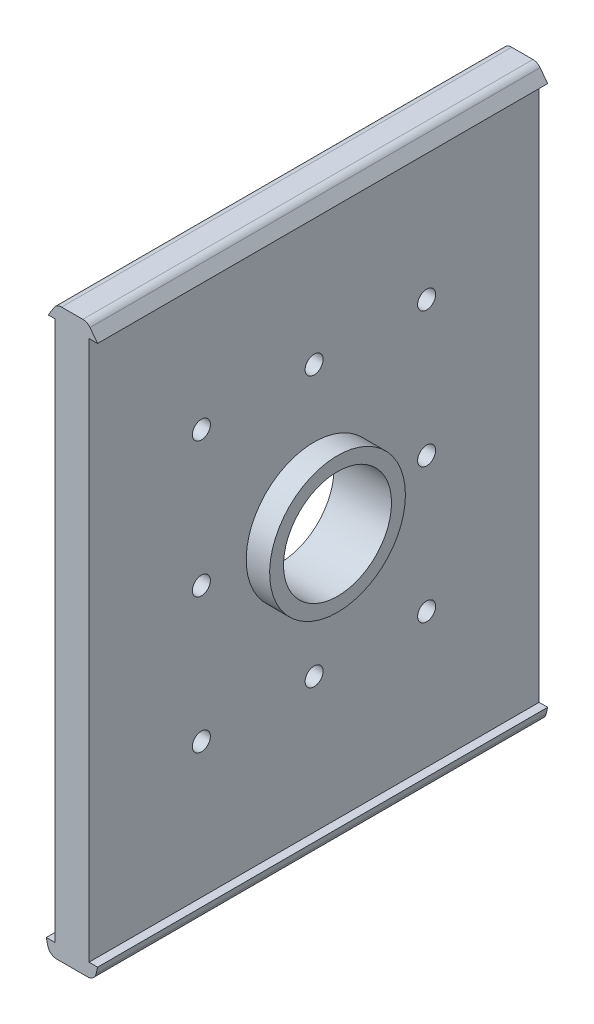
from build123d import *

# Parameters (mm, degrees)
RESSALTO_EXTRUS_O1_DEPTH   = 160
ESBO_O2_W                  = 7.6
ESBO_O2_H                  = 120
CORTE_EXTRUS_O1_DEPTH      = 30
CORTE_EXTRUS_O2_DEPTH      = 30
F_3DSKETCH3_R              = 2
CORTE_EXTRUS_O3_DEPTH      = 70
ESBO_O3_W                  = 45.015344868
ESBO_O3_H                  = 129.478543367
ESBO_O3_W_2                = 37.192593828
CORTE_EXTRUS_O4_DEPTH      = 31.510345968
CORTE_EXTRUS_O4_DEPTH_BACK = 38
ESBO_O4_R                  = 12
CORTE_EXTRUS_O5_DEPTH      = 52.510345968
CORTE_EXTRUS_O5_DEPTH_BACK = 54
ESBO_O5_R                  = 15.084668413
ESBO_O5_R_2                = 12
RESSALTO_EXTRUS_O3_DEPTH   = 9


with BuildPart() as part:
    # Esboço1 → Ressalto-extrusão1 (new body)
    with BuildSketch(Plane.XY):
        with BuildLine():
            Line((-3.8, 21.821375341), (-3.8, -98.178624659))
            Line((-3.8, -98.178624659), (-5.7, -98.178624659))
            Line((-5.7, -98.178624659), (-5.360626179, -99.63308389))
            ThreePointArc((-5.360626179, -99.63308389), (-4.656141559, -100.745296045), (-3.41294376, -101.178624659))
            Line((-3.41294376, -101.178624659), (3.41294376, -101.178624659))
            ThreePointArc((3.41294376, -101.178624659), (4.656141559, -100.745296045), (5.360626179, -99.63308389))
            Line((5.360626179, -99.63308389), (5.7, -98.178624659))
            Line((5.7, -98.178624659), (3.8, -98.178624659))
            Line((3.8, -98.178624659), (3.8, 21.821375341))
            Line((3.8, 21.821375341), (5.7, 21.821375341))
            Line((5.7, 21.821375341), (4.013268169, 24.033911877))
            ThreePointArc((4.013268169, 24.033911877), (3.310139149, 24.613730366), (2.422747768, 24.821375341))
            Line((2.422747768, 24.821375341), (-2.297792791, 24.821375341))
            ThreePointArc((-2.297792791, 24.821375341), (-3.27177376, 24.568189891), (-3.999156919, 23.872736414))
            Line((-3.999156919, 23.872736414), (-5.266799243, 21.821375341))
            Line((-5.266799243, 21.821375341), (-3.8, 21.821375341))
        make_face()
    extrude(amount=RESSALTO_EXTRUS_O1_DEPTH)

    # Esboço2 → Corte-extrusão1 (cut)
    with BuildSketch(Plane.XY):
        with Locations((0, -38.178624659)):
            Rectangle(ESBO_O2_W, ESBO_O2_H)
    extrude(amount=CORTE_EXTRUS_O1_DEPTH, mode=Mode.SUBTRACT)

    # 3DSketch2 → Corte-extrusão2 (cut)
    with BuildSketch(Plane(origin=(-3.8, 21.821375341, 160), x_dir=(0.0632066956560733, -0.9980004577274705, 0), z_dir=(0, 0, -1))):
        Polygon((0, 0), (0.480370887, -7.584803479), (120.240425814, 0), (119.760054927, 7.584803479), align=None)
    extrude(amount=CORTE_EXTRUS_O2_DEPTH, mode=Mode.SUBTRACT)

    # 3DSketch3 → Corte-extrusão3 (cut)
    with BuildSketch(Plane(origin=(3.8, -38.178624659, 80), x_dir=(0, 0.7676852805184269, 0.6408270516101394), z_dir=(1, 0, 0))):
        with Locations(Location((0, 0, 0), (0, 0, 140.146481665))):
            Circle(F_3DSKETCH3_R)
        with Locations(Location((23.030558416, -19.224811548, 0), (0, 0, 140.146481665))):
            Circle(F_3DSKETCH3_R)
        with Locations(Location((-23.030558416, 19.224811548, 0), (0, 0, 140.146481665))):
            Circle(F_3DSKETCH3_R)
        with Locations(Location((-39.051234706, 0.032679535, 0), (0, 0, 140.146481665))):
            Circle(F_3DSKETCH3_R)
        with Locations(Location((-16.02067629, -19.192132013, 0), (0, 0, 140.146481665))):
            Circle(F_3DSKETCH3_R)
        with Locations(Location((7.009882125, -38.416943561, 0), (0, 0, 140.146481665))):
            Circle(F_3DSKETCH3_R)
        with Locations(Location((-6.982602808, 38.449623097, 0), (0, 0, 140.146481665))):
            Circle(F_3DSKETCH3_R)
        with Locations(Location((16.047955607, 19.224811548, 0), (0, 0, 140.146481665))):
            Circle(F_3DSKETCH3_R)
        with Locations(Location((39.078514023, 0, 0), (0, 0, 140.146481665))):
            Circle(F_3DSKETCH3_R)
    extrude(amount=-CORTE_EXTRUS_O3_DEPTH, mode=Mode.SUBTRACT)

    # Esboço3 → Corte-extrusão4 (cut, two sides)
    with BuildSketch(Plane(origin=(0, 0, 0), x_dir=(0, 0, -1), z_dir=(1, 0, 0))) as corte_extrus_o4_sk:
        with Locations((-7.492327566, -39.917896343)):
            Rectangle(ESBO_O3_W, ESBO_O3_H)
        with Locations((-148.596296914, -39.917896343)):
            Rectangle(ESBO_O3_W_2, ESBO_O3_H)
    extrude(amount=CORTE_EXTRUS_O4_DEPTH, mode=Mode.SUBTRACT)
    extrude(corte_extrus_o4_sk.sketch, amount=-CORTE_EXTRUS_O4_DEPTH_BACK, mode=Mode.SUBTRACT)

    # Esboço4 → Corte-extrusão5 (cut, two sides)
    with BuildSketch(Plane(origin=(0, 0, 0), x_dir=(0, 0, -1), z_dir=(1, 0, 0))) as corte_extrus_o5_sk:
        with Locations(Location((-80, -38.178624659, 0), (0, 0, 270))):
            Circle(ESBO_O4_R)
    extrude(amount=CORTE_EXTRUS_O5_DEPTH, mode=Mode.SUBTRACT)
    extrude(corte_extrus_o5_sk.sketch, amount=-CORTE_EXTRUS_O5_DEPTH_BACK, mode=Mode.SUBTRACT)

    # Esboço5 → Ressalto-extrusão3 (add)
    with BuildSketch(Plane(origin=(0, 0, 0), x_dir=(0, 0, -1), z_dir=(1, 0, 0))):
        with Locations(Location((-80, -38.178624659, 0), (0, 0, 270))):
            Circle(ESBO_O5_R)
        with Locations((-80, -38.178624659)):
            Circle(ESBO_O5_R_2, mode=Mode.SUBTRACT)
    extrude(amount=RESSALTO_EXTRUS_O3_DEPTH)


solid = part.part
